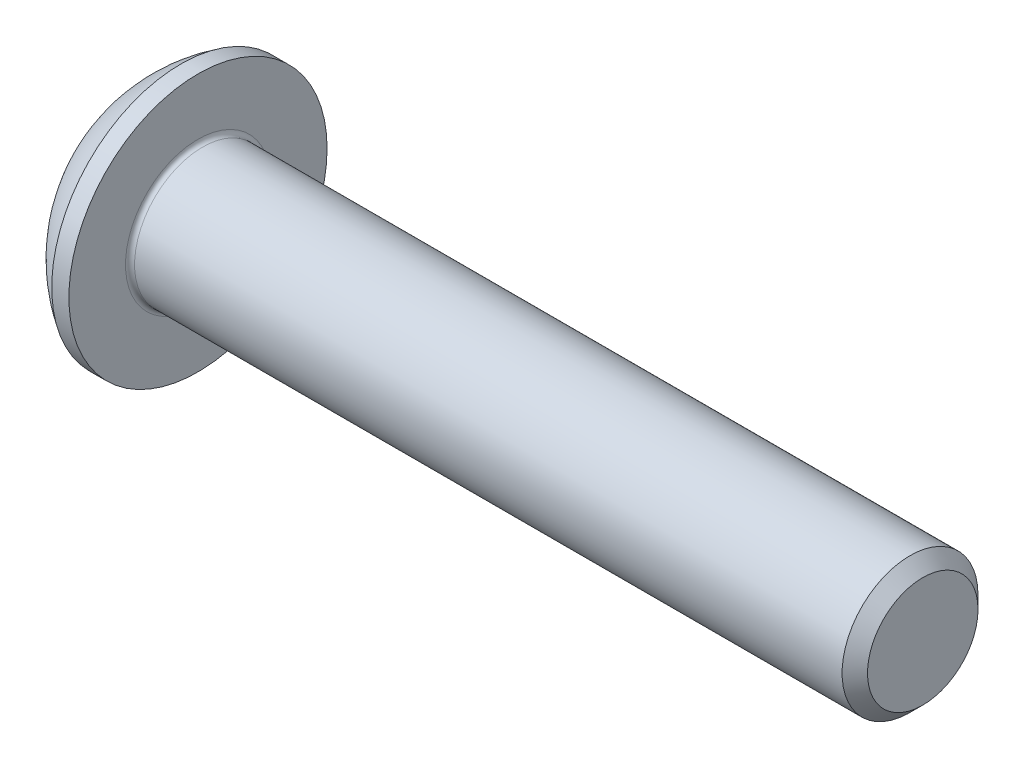
from build123d import *

# Parameters (mm, degrees)
FILLET_1_R  = 0.1
HEX_2_DEPTH = 1.04


with BuildPart() as part:
    # Эскиз1 → Body (revolve)
    with BuildSketch(Plane.XY):
        with BuildLine():
            Line((0, 1.425), (0, 0))
            Line((0, 0), (17.65, 0))
            Line((17.65, 0), (17.65, 1.2195))
            Line((17.65, 1.2195), (17.3695, 1.5))
            Line((17.3695, 1.5), (1.65, 1.5))
            Line((1.65, 1.5), (1.65, 2.85))
            Line((1.65, 2.85), (1.271128829, 2.85))
            ThreePointArc((1.271128829, 2.85), (0.531880191, 2.229988425), (0, 1.425))
        make_face()
    revolve(axis=Axis((-3.643489966, 0, 0), (-1, 0, 0)))

    # Скругление1
    fillet_1_edges = [part.edges().sort_by_distance(p)[0] for p in [
        (1.65, -1.5, 0),
    ]]
    fillet(fillet_1_edges, radius=FILLET_1_R)

    # Эскиз2 → Вырез-Повернуть1 (revolve, cut)
    with BuildSketch(Plane.XY):
        Polygon((0, 0), (0, 1), (1.04, 1), (1.617350269, 0), align=None)
    revolve(axis=Axis((1.617350269, 0, 0), (-1, 0, 0)), mode=Mode.SUBTRACT)

    # Эскиз3 → Hex 2 (cut)
    with BuildSketch(Plane.ZY):
        Polygon((-1, -0.577350269), (0, -1.154700538), (1, -0.577350269), (1, 0.577350269), (0, 1.154700538), (-1, 0.577350269), align=None)
    extrude(amount=-HEX_2_DEPTH, mode=Mode.SUBTRACT)


solid = part.part
